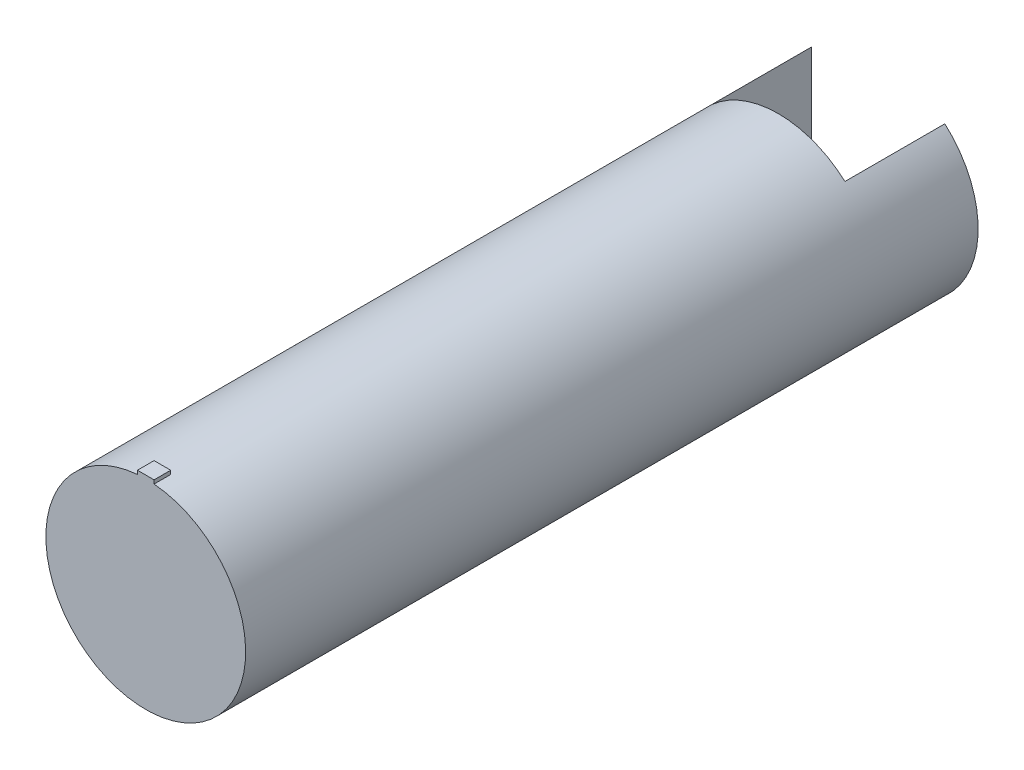
from build123d import *

# Parameters (mm, degrees)
SKETCH1_R           = 30
BOSS_EXTRUDE1_DEPTH = 220
SKETCH2_W           = 40
SKETCH2_H           = 60
CUT_EXTRUDE1_DEPTH  = 30
SKETCH3_R           = 2.5
CUT_EXTRUDE3_DEPTH  = 5
SKETCH4_W           = 5
SKETCH4_H           = 5
BOSS_EXTRUDE2_DEPTH = 31


with BuildPart() as part:
    # Sketch1 → Boss-Extrude1 (new body)
    with BuildSketch(Plane.XY):
        Circle(SKETCH1_R)
    extrude(amount=BOSS_EXTRUDE1_DEPTH)

    # Sketch2 → Cut-Extrude1 (cut)
    with BuildSketch(Plane.XY):
        Rectangle(SKETCH2_W, SKETCH2_H)
    extrude(amount=CUT_EXTRUDE1_DEPTH, mode=Mode.SUBTRACT)

    # Sketch3 → Cut-Extrude3 (cut)
    with BuildSketch(Plane.ZY.offset(-20)):
        with Locations((7.04424443, 0)):
            Circle(SKETCH3_R)
    cut_extrude3 = extrude(amount=-CUT_EXTRUDE3_DEPTH, mode=Mode.SUBTRACT)

    # Mirror1: Cut-Extrude3 across plane
    add(cut_extrude3.mirror(Plane.ZY), mode=Mode.SUBTRACT)

    # Sketch4 → Boss-Extrude2 (add)
    with BuildSketch(Plane(origin=(0, 0, 0), x_dir=(1, 0, 0), z_dir=(0, 1, 0))):
        with Locations((0, -217.5)):
            Rectangle(SKETCH4_W, SKETCH4_H)
    extrude(amount=BOSS_EXTRUDE2_DEPTH)


solid = part.part
